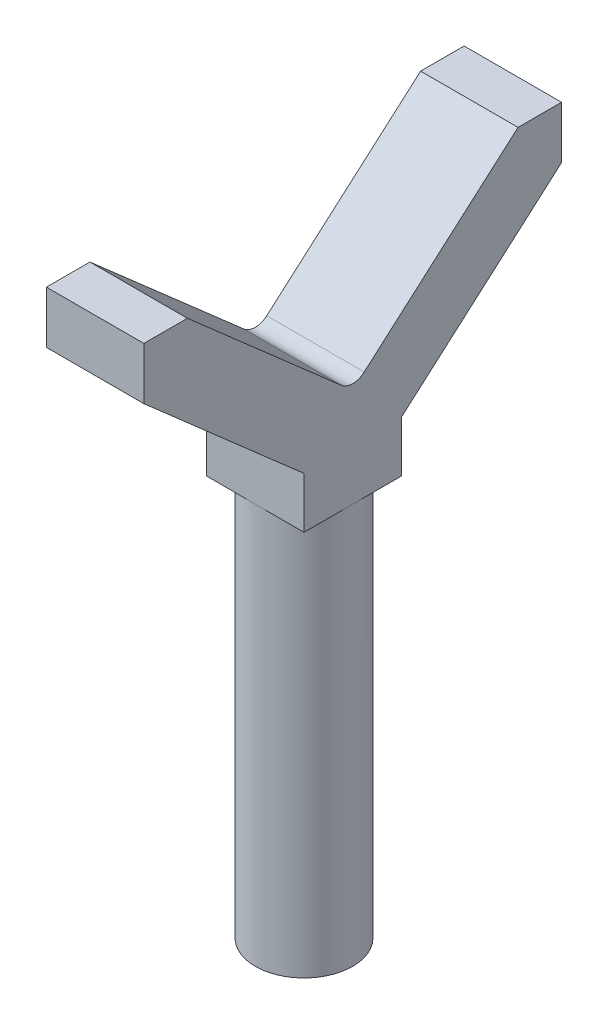
from build123d import *

# Parameters (mm, degrees)
SKETCH1_R           = 28
BOSS_EXTRUDE1_DEPTH = 230
BOSS_EXTRUDE2_DEPTH = 28


with BuildPart() as part:
    # Sketch1 → Boss-Extrude1 (new body)
    with BuildSketch(Plane(origin=(0, 0, 0), x_dir=(1, 0, 0), z_dir=(0, 1, 0))):
        Circle(SKETCH1_R)
    extrude(amount=BOSS_EXTRUDE1_DEPTH)

    # Sketch2 → Boss-Extrude2 (add, symmetric)
    with BuildSketch(Plane(origin=(0, 0, 0), x_dir=(0, 0, -1), z_dir=(1, 0, 0))):
        with BuildLine():
            Line((6.592878428, 292.481093562), (95, 370))
            Line((95, 370), (120, 370))
            Line((120, 370), (120, 340))
            Line((120, 340), (28, 259.330713798))
            Line((28, 259.330713798), (28, 230))
            Line((28, 230), (-28, 230))
            Line((-28, 230), (-28, 259.330713798))
            Line((-28, 259.330713798), (-120, 340))
            Line((-120, 340), (-120, 370))
            Line((-120, 370), (-95, 370))
            Line((-95, 370), (-6.592878428, 292.481093562))
            ThreePointArc((-6.592878428, 292.481093562), (0, 290), (6.592878428, 292.481093562))
        make_face()
    extrude(amount=BOSS_EXTRUDE2_DEPTH, both=True)


solid = part.part
